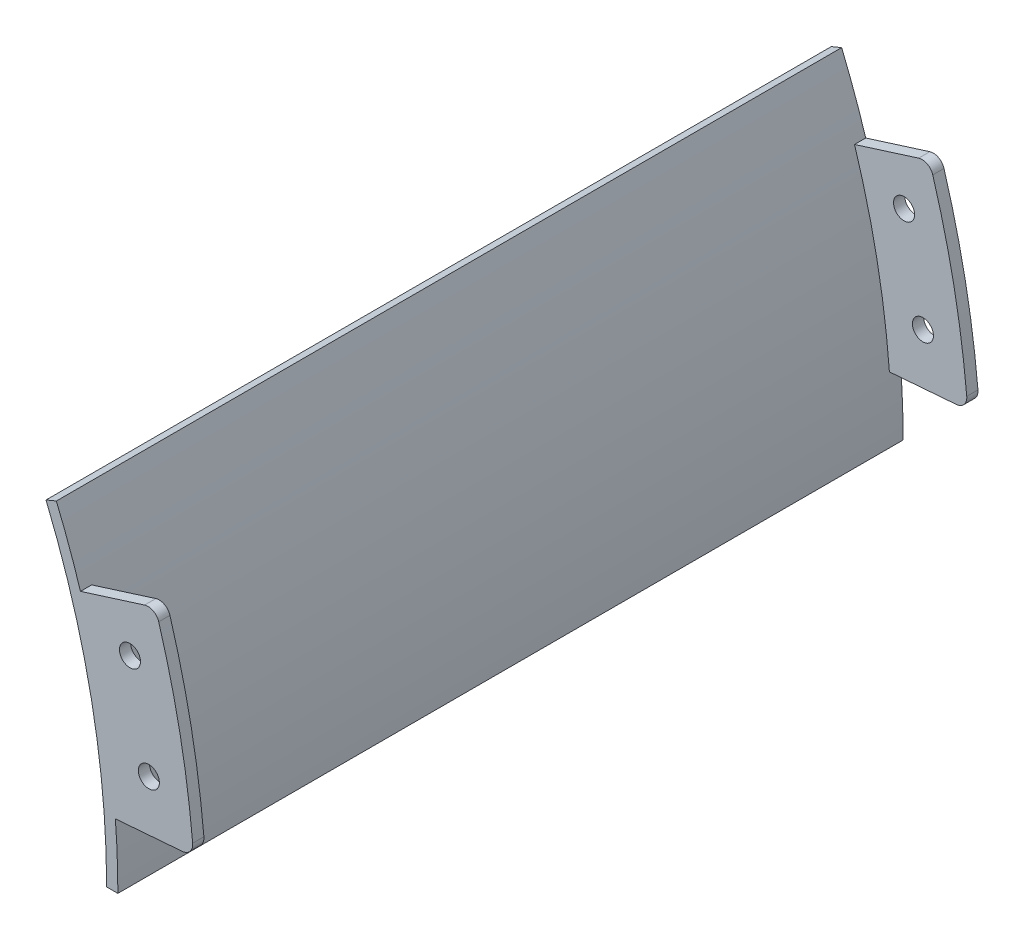
from build123d import *

# Parameters (mm, degrees)
BOSS_EXTRUDE1_DEPTH = 177.8
SKETCH2_R           = 2.38125
BOSS_EXTRUDE2_DEPTH = 2.54


with BuildPart() as part:
    # Sketch1 → Boss-Extrude1 (new body)
    with BuildSketch(Plane.XY):
        with BuildLine():
            Line((166.612434893, 69.013130193), (168.959088906, 69.985146111))
            ThreePointArc((168.959088906, 69.985146111), (179.36601208, 35.67811809), (182.88, 0))
            Line((182.88, 0), (180.34, 0))
            ThreePointArc((180.34, 0), (176.874817468, 35.182588672), (166.612434893, 69.013130193))
        make_face()
    extrude(amount=BOSS_EXTRUDE1_DEPTH)

    # Sketch2 → Boss-Extrude2 (add)
    with BuildSketch(Plane.XY.offset(177.8)):
        with BuildLine():
            Line((174.415755953, 54.993076613), (188.934873176, 59.570936689))
            ThreePointArc((188.934873176, 59.570936689), (190.885925939, 59.39393849), (192.130700085, 57.881168655))
            ThreePointArc((192.130700085, 57.881168655), (196.973310631, 38.287733012), (199.823150498, 18.306941989))
            ThreePointArc((199.823150498, 18.306941989), (199.235709562, 16.43802562), (197.493029633, 15.543038518))
            Line((197.493029633, 15.543038518), (182.316241993, 14.348599427))
            ThreePointArc((182.316241993, 14.348599427), (179.519979309, 34.895149074), (174.415755953, 54.993076613))
        make_face()
        with Locations((185.626529875, 48.001162801)):
            Circle(SKETCH2_R, mode=Mode.SUBTRACT)
        with Locations((189.904635813, 26.411162801)):
            Circle(SKETCH2_R, mode=Mode.SUBTRACT)
    boss_extrude2 = extrude(amount=-BOSS_EXTRUDE2_DEPTH)

    # Mirror1: Boss-Extrude2 across plane
    add(boss_extrude2.mirror(Plane.XY.offset(88.9)))


solid = part.part
